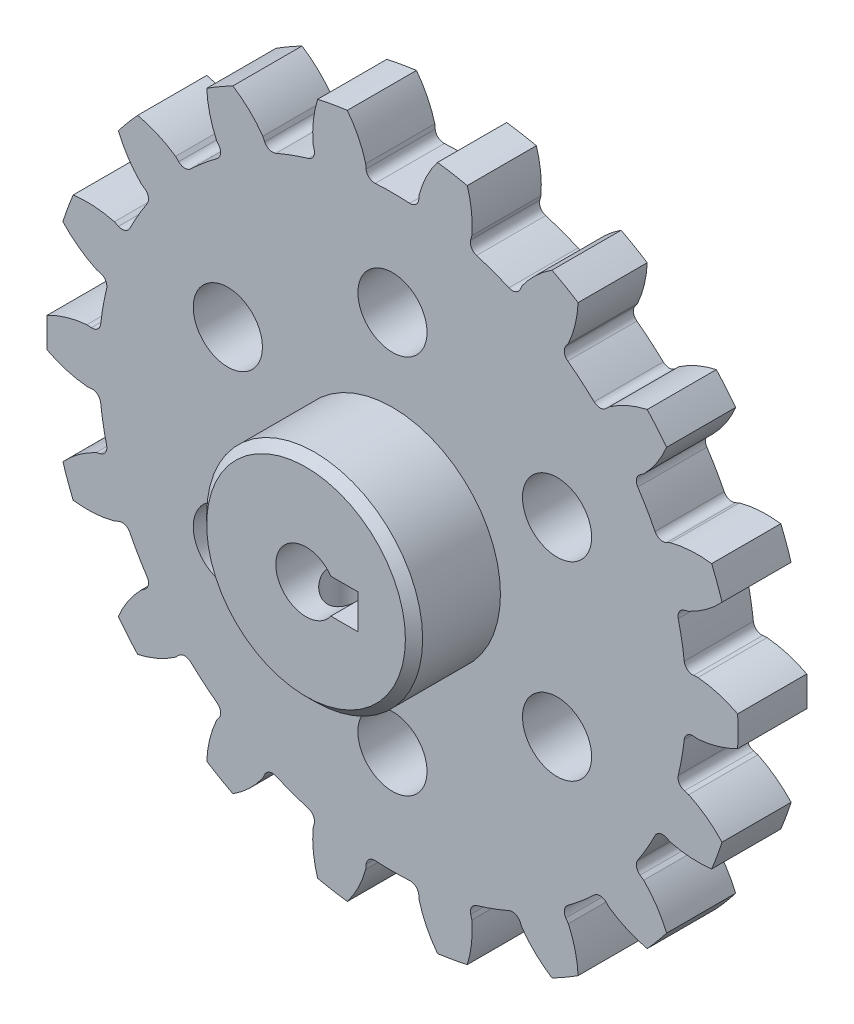
from build123d import *

# Parameters (mm, degrees)
BOSS_EXTRU_1_DEPTH                 = 8
CONG_1_R                           = 1
R_P_TITION_CIRCULAIRE2_COUNT       = 18
CONG_1_OF_R_P_TITION_CIRCULAIRE2_R = 1
ESQUISSE3_R                        = 12.5
BOSS_EXTRU_2_DEPTH                 = 10
ESQUISSE7_W                        = 6
ESQUISSE7_H                        = 4
ENL_V_MAT_EXTRU_2_DEPTH            = 10
ESQUISSE5_R                        = 3.5
ENL_V_MAT_EXTRU_3_DEPTH            = 18
ENL_V_MAT_EXTRU_4_REACH            = 41.651
ESQUISSE8_R                        = 2.5
CHANFREIN1_SIZE                    = 1
ESQUISSE9_R                        = 4
ENL_V_MAT_EXTRU_5_DEPTH            = 8
R_P_TITION_CIRCULAIRE3_COUNT       = 6


with BuildPart() as part:
    # Esquisse1 → Boss.-Extru.1 (new body)
    with BuildSketch(Plane.XY):
        with BuildLine():
            Line((33.870619735, -2.963295253), (35.364911782, -3.094028868))
            ThreePointArc((35.364911782, -3.094028868), (37.724726959, -2.640126003), (39.954644748, -1.744457463))
            ThreePointArc((39.954644748, -1.744457463), (39.992708945, 0), (39.954644748, 1.744457463))
            ThreePointArc((39.954644748, 1.744457463), (37.724726959, 2.640126003), (35.364911782, 3.094028868))
            Line((35.364911782, 3.094028868), (33.870619735, 2.963295253))
            ThreePointArc((33.870619735, 2.963295253), (33.709125287, 4.437890535), (33.483463602, 5.904038041))
            Line((33.483463602, 5.904038041), (0, 0))
            Line((0, 0), (33.483463602, -5.904038041))
            ThreePointArc((33.483463602, -5.904038041), (33.709125287, -4.437890535), (33.870619735, -2.963295253))
        make_face()
    boss_extru_1 = extrude(amount=BOSS_EXTRU_1_DEPTH)

    # Congé1
    cong_1_edges = [part.edges().sort_by_distance(p)[0] for p in [
        (33.870619735, -2.963295253, 4),
        (33.870619735, 2.963295253, 4),
    ]]
    fillet(cong_1_edges, radius=CONG_1_R)

    # Répétition circulaire2: Boss.-Extru.1 ×18 about axis
    r_p_tition_circulaire2_axis = Axis((0, 0, 0), (0, 0, 1))
    for i in range(1, R_P_TITION_CIRCULAIRE2_COUNT):
        add(boss_extru_1.rotate(r_p_tition_circulaire2_axis, i * 360 / R_P_TITION_CIRCULAIRE2_COUNT))

    # Congé1 of Répétition circulaire2
    cong_1_of_r_p_tition_circulaire2_edges = [part.edges().sort_by_distance(p)[0] for p in [
        (32.841478094, 8.799847533, 4),
        (30.814464759, 14.369020899, 4),
        (27.851169506, 19.501598836, 4),
        (24.04163056, 24.04163056, 4),
        (19.501598836, 27.851169506, 4),
        (14.369020899, 30.814464759, 4),
        (8.799847533, 32.841478094, 4),
        (2.963295253, 33.870619735, 4),
        (-2.963295253, 33.870619735, 4),
        (-8.799847533, 32.841478094, 4),
        (-14.369020899, 30.814464759, 4),
        (-19.501598836, 27.851169506, 4),
        (-24.04163056, 24.04163056, 4),
        (-27.851169506, 19.501598836, 4),
        (-30.814464759, 14.369020899, 4),
        (-32.841478094, 8.799847533, 4),
        (-33.870619735, 2.963295253, 4),
        (-33.870619735, -2.963295253, 4),
        (-32.841478094, -8.799847533, 4),
        (-30.814464759, -14.369020899, 4),
        (-27.851169506, -19.501598836, 4),
        (-24.04163056, -24.04163056, 4),
        (-19.501598836, -27.851169506, 4),
        (-14.369020899, -30.814464759, 4),
        (-8.799847533, -32.841478094, 4),
        (-2.963295253, -33.870619735, 4),
        (2.963295253, -33.870619735, 4),
        (8.799847533, -32.841478094, 4),
        (14.369020899, -30.814464759, 4),
        (19.501598836, -27.851169506, 4),
        (24.04163056, -24.04163056, 4),
        (27.851169506, -19.501598836, 4),
        (30.814464759, -14.369020899, 4),
        (32.841478094, -8.799847533, 4),
    ]]
    fillet(cong_1_of_r_p_tition_circulaire2_edges, radius=CONG_1_OF_R_P_TITION_CIRCULAIRE2_R)

    # Esquisse3 → Boss.-Extru.2 (add)
    with BuildSketch(Plane.XY.offset(8)):
        Circle(ESQUISSE3_R)
    extrude(amount=BOSS_EXTRU_2_DEPTH)

    # Esquisse7 → Enlèv. mat.-Extru.2 (cut)
    with BuildSketch(Plane.XY.offset(18)):
        with Locations((3, 0)):
            Rectangle(ESQUISSE7_W, ESQUISSE7_H)
    extrude(amount=-ENL_V_MAT_EXTRU_2_DEPTH, mode=Mode.SUBTRACT)

    # Esquisse5 → Enlèv. mat.-Extru.3 (cut)
    with BuildSketch(Plane.XY.offset(18)):
        Circle(ESQUISSE5_R)
    extrude(amount=-ENL_V_MAT_EXTRU_3_DEPTH, mode=Mode.SUBTRACT)

    # Esquisse8 → Enlèv. mat.-Extru.4 (cut, up to next)
    with BuildSketch(Plane(origin=(0, 0, 0), x_dir=(1, 0, 0), z_dir=(0, 1, 0)), mode=Mode.PRIVATE) as enl_v_mat_extru_4_sk1:
        with Locations((0, -13)):
            Circle(ESQUISSE8_R)
    enl_v_mat_extru_4_tool1 = extrude(enl_v_mat_extru_4_sk1.sketch, amount=-ENL_V_MAT_EXTRU_4_REACH, mode=Mode.PRIVATE) & part.part
    add(enl_v_mat_extru_4_tool1.solids().sort_by_distance((0, 0, 13))[0], mode=Mode.SUBTRACT)

    # Chanfrein1
    chanfrein1_edges = [part.edges().sort_by_distance(p)[0] for p in [
        (-12.5, 0, 18),
    ]]
    chamfer(chanfrein1_edges, length=CHANFREIN1_SIZE)

    # Esquisse9 → Enlèv. mat.-Extru.5 (cut)
    with BuildSketch(Plane.XY.offset(8)):
        with Locations((0, 22)):
            Circle(ESQUISSE9_R)
    enl_v_mat_extru_5 = extrude(amount=-ENL_V_MAT_EXTRU_5_DEPTH, mode=Mode.SUBTRACT)

    # Répétition circulaire3: Enlèv. mat.-Extru.5 ×6 about axis
    r_p_tition_circulaire3_axis = Axis((0, 0, 0), (0, 0, 1))
    for i in range(1, R_P_TITION_CIRCULAIRE3_COUNT):
        add(enl_v_mat_extru_5.rotate(r_p_tition_circulaire3_axis, i * 360 / R_P_TITION_CIRCULAIRE3_COUNT), mode=Mode.SUBTRACT)


solid = part.part
